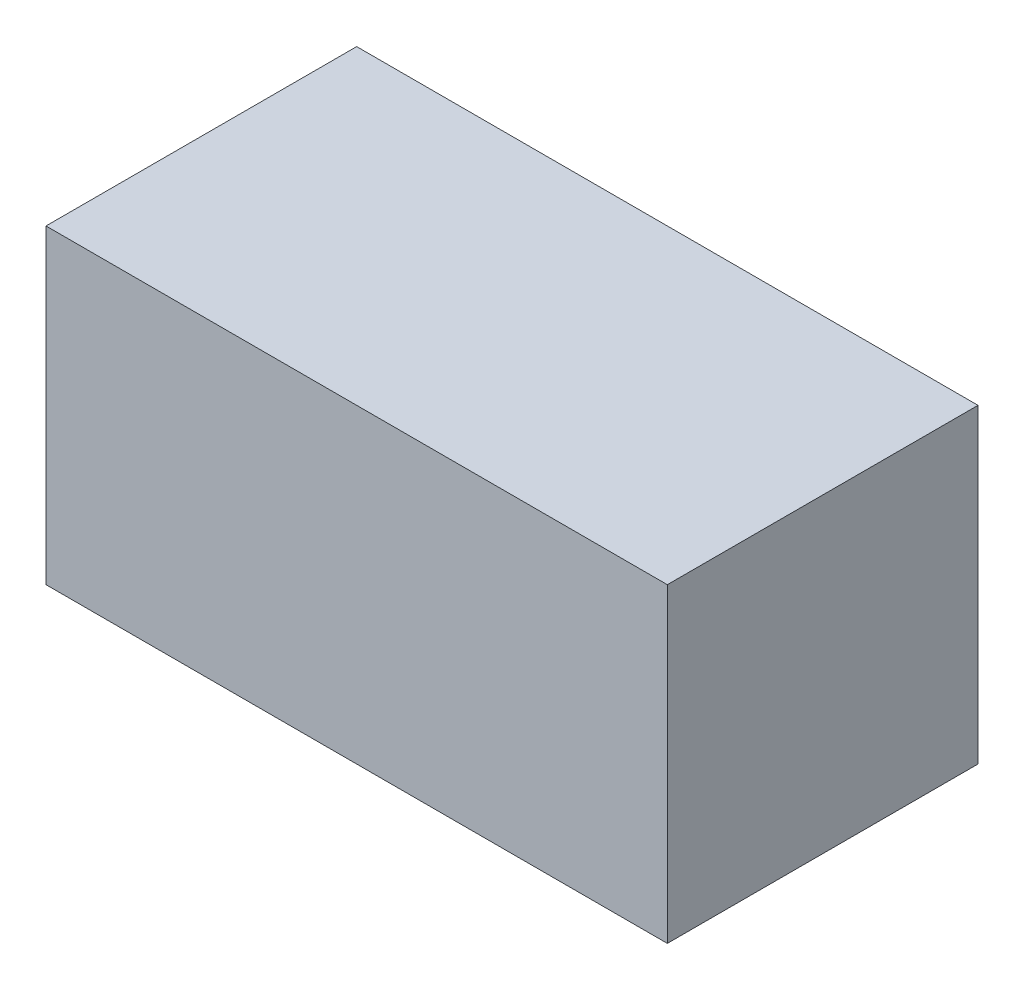
from build123d import *

# Parameters (mm, degrees)
SKETCH2_W           = 30
SKETCH2_H           = 15
BOSS_EXTRUDE1_DEPTH = 15


with BuildPart() as part:
    # Sketch2 → Boss-Extrude1 (new body)
    with BuildSketch(Plane(origin=(0, 0, 0), x_dir=(1, 0, 0), z_dir=(0, 1, 0))):
        Rectangle(SKETCH2_W, SKETCH2_H)
    extrude(amount=BOSS_EXTRUDE1_DEPTH)


solid = part.part
